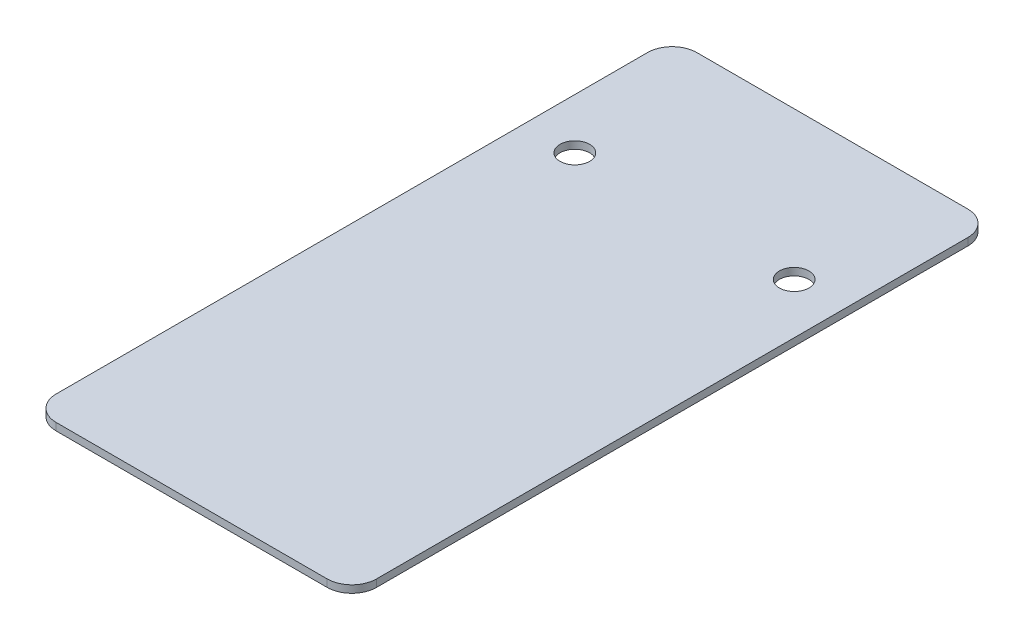
from build123d import *

# Parameters (mm, degrees)
SKETCH1_W           = 130
SKETCH1_H           = 120
BOSS_EXTRUDE1_DEPTH = 3
CUT_EXTRUDE1_START  = -4
SKETCH2_R           = 6
CUT_EXTRUDE1_DEPTH  = 5
SKETCH3_W           = 130
SKETCH3_H           = 3
BOSS_EXTRUDE2_DEPTH = 140
FILLET1_R           = 10


with BuildPart() as part:
    # Sketch1 → Boss-Extrude1 (new body)
    with BuildSketch(Plane(origin=(0, 0, 0), x_dir=(1, 0, 0), z_dir=(0, 1, 0))):
        Rectangle(SKETCH1_W, SKETCH1_H)
    extrude(amount=BOSS_EXTRUDE1_DEPTH)

    # Sketch2 → Cut-Extrude1 (cut)
    with BuildSketch(Plane(origin=(0, 3, 0), x_dir=(1, 0, 0), z_dir=(0, 1, 0)).offset(CUT_EXTRUDE1_START)):
        with Locations((44.5, 0)):
            Circle(SKETCH2_R)
    cut_extrude1 = extrude(amount=CUT_EXTRUDE1_DEPTH, mode=Mode.SUBTRACT)

    # Mirror1: Cut-Extrude1 across plane
    add(cut_extrude1.mirror(Plane(origin=(0, 0, 0), x_dir=(0, 0, 1), z_dir=(1, 0, 0))), mode=Mode.SUBTRACT)

    # Sketch3 → Boss-Extrude2 (add)
    with BuildSketch(Plane.XY.offset(60)):
        with Locations((0, 1.5)):
            Rectangle(SKETCH3_W, SKETCH3_H)
    extrude(amount=BOSS_EXTRUDE2_DEPTH)

    # Fillet1
    fillet1_edges = [part.edges().sort_by_distance(p)[0] for p in [
        (-65, 1.5, 200),
        (65, 1.5, 200),
        (-65, 1.5, -60),
        (65, 1.5, -60),
    ]]
    fillet(fillet1_edges, radius=FILLET1_R)


solid = part.part
